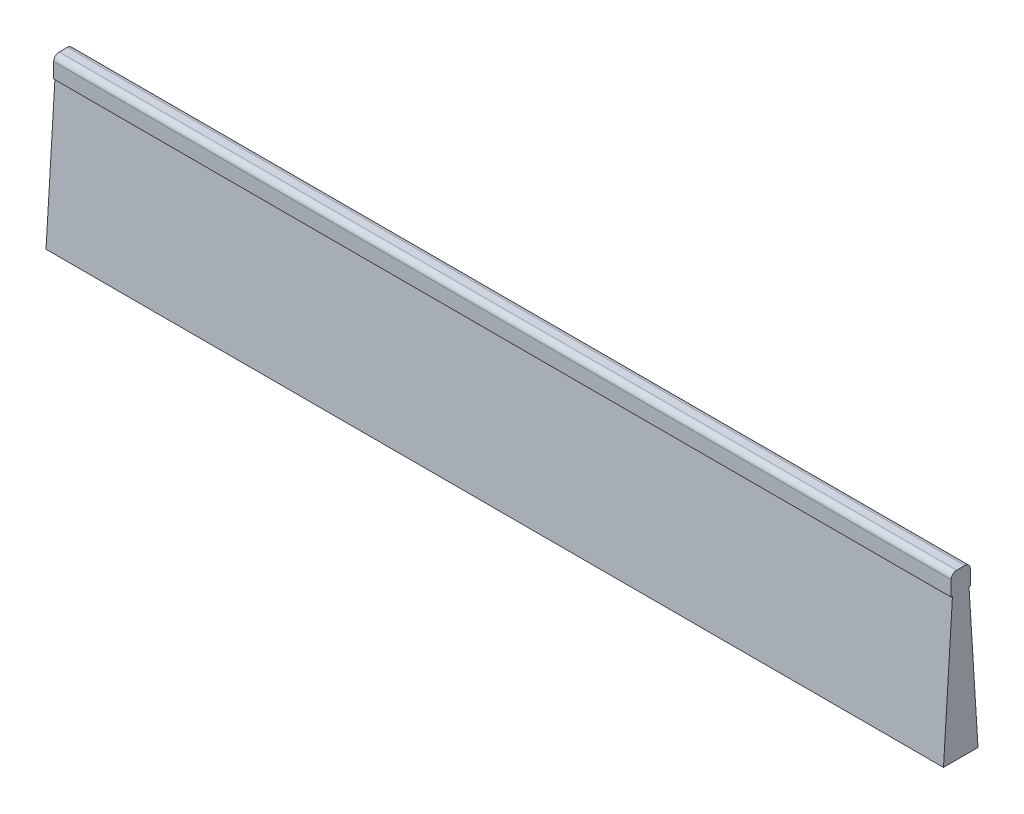
from build123d import *

# Parameters (mm, degrees)
BOSS_EXTRUDE1_DEPTH = 61.9125
FILLET1_R           = 0.762


with BuildPart() as part:
    # Sketch1 → Boss-Extrude1 (new body, symmetric)
    with BuildSketch(Plane(origin=(0, 0, 0), x_dir=(0, 0, -1), z_dir=(1, 0, 0))):
        Polygon((-1.3208, 0), (1.3208, 0), (1.3208, -2.8448), (1.143, -2.8448), (2.38125, -22.6568), (-2.38125, -22.6568), (-1.143, -2.8448), (-1.3208, -2.8448), align=None)
    extrude(amount=BOSS_EXTRUDE1_DEPTH, both=True)

    # Fillet1
    fillet1_edges = [part.edges().sort_by_distance(p)[0] for p in [
        (0, 0, 1.3208),
        (0, 0, -1.3208),
    ]]
    fillet(fillet1_edges, radius=FILLET1_R)


solid = part.part
